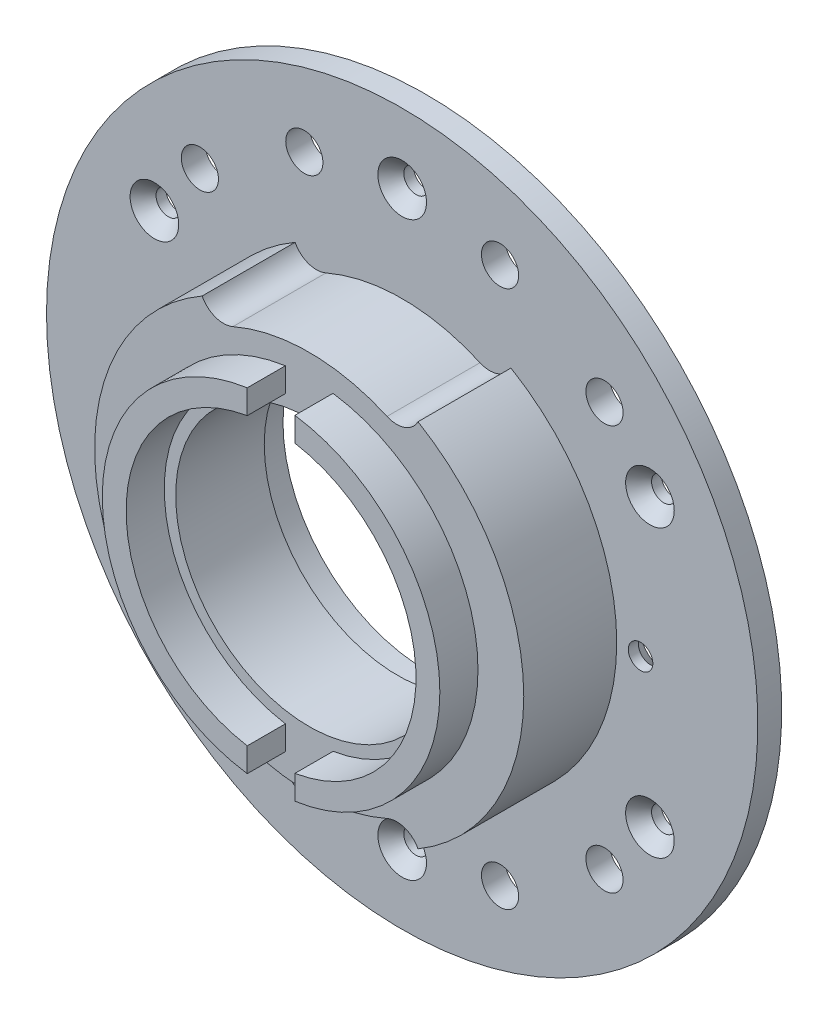
from build123d import *

# Parameters (mm, degrees)
SKETCH1_R               = 28.575
BOSS_EXTRUDE1_DEPTH     = 4.7625
SKETCH2_R               = 17.78
CUT_EXTRUDE1_DEPTH      = 5.7625
SKETCH9_R               = 28.575
SKETCH9_R_2             = 17.78
BOSS_EXTRUDE4_DEPTH     = 7.62
SKETCH4_R               = 22.479
SKETCH4_R_2             = 19.304
BOSS_EXTRUDE2_DEPTH     = 5.08
SKETCH5_W               = 6.35
SKETCH5_H               = 50.8
CUT_EXTRUDE3_DEPTH      = 5.08
CUT_EXTRUDE4_DEPTH      = 13.3825
SKETCH10_R              = 19.05
CUT_EXTRUDE5_DEPTH      = 0.59182
SKETCH11_R              = 47.371
SKETCH11_R_2            = 19.05
BOSS_EXTRUDE5_DEPTH     = 3.175
CIRPATTERN1_COUNT       = 6
SKETCH19_R              = 2.4765
CUT_EXTRUDE7_DEPTH      = 21.6375
CIRPATTERN2_COUNT       = 2
CIRPATTERN2_ANGLE       = 25
MIRROR3_COPY_1_SKETCH_R = 2.4765
MIRROR3_COPY_1_DEPTH    = 21.6375
MIRROR4_COPY_1_SKETCH_R = 2.4765
MIRROR4_COPY_1_DEPTH    = 21.6375
MIRROR4_COPY_2_SKETCH_R = 2.4765
MIRROR4_COPY_2_DEPTH    = 21.6375
MIRROR4_COPY_3_SKETCH_R = 2.4765
MIRROR4_COPY_3_DEPTH    = 21.6375


with BuildPart() as part:
    # Sketch1 → Boss-Extrude1 (new body)
    with BuildSketch(Plane.XY):
        Circle(SKETCH1_R)
    extrude(amount=BOSS_EXTRUDE1_DEPTH)

    # Sketch2 → Cut-Extrude1 (cut, through all)
    with BuildSketch(Plane.XY.offset(4.7625)):
        Circle(SKETCH2_R)
    extrude(amount=-CUT_EXTRUDE1_DEPTH, mode=Mode.SUBTRACT)

    # Sketch9 → Boss-Extrude4 (add)
    with BuildSketch(Plane(origin=(0, 0, 0), x_dir=(-1, 0, 0), z_dir=(0, 0, -1))):
        Circle(SKETCH9_R)
        Circle(SKETCH9_R_2, mode=Mode.SUBTRACT)
    extrude(amount=BOSS_EXTRUDE4_DEPTH)

    # Sketch4 → Boss-Extrude2 (add)
    with BuildSketch(Plane.XY.offset(4.7625)):
        Circle(SKETCH4_R)
        Circle(SKETCH4_R_2, mode=Mode.SUBTRACT)
    extrude(amount=BOSS_EXTRUDE2_DEPTH)

    # Sketch5 → Cut-Extrude3 (cut)
    with BuildSketch(Plane.XY.offset(9.8425)):
        Rectangle(SKETCH5_W, SKETCH5_H)
    extrude(amount=-CUT_EXTRUDE3_DEPTH, mode=Mode.SUBTRACT)

    # Sketch7 → Cut-Extrude4 (cut, through all)
    with BuildSketch(Plane.XY.offset(4.7625)):
        with BuildLine():
            ThreePointArc((12.960022594, 28.984484028), (0.147829333, 31.749655848), (-12.689557657, 29.103910845))
            ThreePointArc((-12.689557657, 29.103910845), (-14.330992976, 24.924563995), (-10.151646126, 23.283128676))
            ThreePointArc((-10.151646126, 23.283128676), (0.118263466, 25.399724679), (10.368018075, 23.187587222))
            ThreePointArc((10.368018075, 23.187587222), (14.562468737, 24.790033366), (12.960022594, 28.984484028))
        make_face()
    cut_extrude4 = extrude(amount=-CUT_EXTRUDE4_DEPTH, mode=Mode.SUBTRACT)

    # Mirror1: Cut-Extrude4 across plane
    add(cut_extrude4.mirror(Plane.ZX), mode=Mode.SUBTRACT)

    # Sketch10 → Cut-Extrude5 (cut)
    with BuildSketch(Plane(origin=(0, 0, -7.62), x_dir=(-1, 0, 0), z_dir=(0, 0, -1))):
        Circle(SKETCH10_R)
    extrude(amount=-CUT_EXTRUDE5_DEPTH, mode=Mode.SUBTRACT)

    # Sketch11 → Boss-Extrude5 (add)
    with BuildSketch(Plane(origin=(0, 0, -7.62), x_dir=(-1, 0, 0), z_dir=(0, 0, -1))):
        Circle(SKETCH11_R)
        Circle(SKETCH11_R_2, mode=Mode.SUBTRACT)
    extrude(amount=BOSS_EXTRUDE5_DEPTH)

    # Sketch12 → CSK for #4 Flat Head Socket Cap Screw1 (revolve, cut)
    with BuildSketch(Plane(origin=(-31.75, 0, -10.795), x_dir=(0, 1, 0), z_dir=(1, 0, 0))):
        Polygon((0, 0), (0, 6.060574487), (1.63195, 5.08), (1.63195, 1.848124365), (3.2385, 0), align=None)
    csk_for_4_flat_head_socket_cap_screw1 = revolve(axis=Axis((-31.75, 0, -17.145), (0, 0, 1)), mode=Mode.SUBTRACT)

    # Mirror2: CSK for #4 Flat Head Socket Cap Screw1 across plane
    add(csk_for_4_flat_head_socket_cap_screw1.mirror(Plane(origin=(0, 0, 0), x_dir=(0, 0, 1), z_dir=(1, 0, 0))), mode=Mode.SUBTRACT)

    # Sketch16 → CSK for #4 Flat Head Socket Cap Screw3 (revolve, cut)
    with BuildSketch(Plane(origin=(0, 38.1, -7.62), x_dir=(0, -1, 0), z_dir=(1, 0, 0))):
        Polygon((0, 0), (0, 4.155574487), (1.63195, 3.175), (1.63195, 1.848124365), (3.2385, 0), align=None)
    csk_for_4_flat_head_socket_cap_screw3 = revolve(axis=Axis((0, 38.1, -1.27), (0, 0, -1)), mode=Mode.SUBTRACT)

    # CirPattern1: CSK for #4 Flat Head Socket Cap Screw3 ×6 about axis
    cirpattern1_axis = Axis((0, 0, 0), (0, 0, 1))
    for i in range(1, CIRPATTERN1_COUNT):
        add(csk_for_4_flat_head_socket_cap_screw3.rotate(cirpattern1_axis, i * 360 / CIRPATTERN1_COUNT), mode=Mode.SUBTRACT)

    # Sketch19 → Cut-Extrude7 (cut, through all)
    with BuildSketch(Plane(origin=(0, 0, -10.795), x_dir=(-1, 0, 0), z_dir=(0, 0, -1))):
        with Locations((13.030967461, 35.802288852)):
            Circle(SKETCH19_R)
    cut_extrude7 = extrude(amount=-CUT_EXTRUDE7_DEPTH, mode=Mode.SUBTRACT)

    # CirPattern2: Cut-Extrude7 ×2 about axis
    cirpattern2_axis = Axis((0, 0, -10.795), (0, 0, 1))
    for i in range(1, CIRPATTERN2_COUNT):
        add(cut_extrude7.rotate(cirpattern2_axis, i * CIRPATTERN2_ANGLE / (CIRPATTERN2_COUNT - 1)), mode=Mode.SUBTRACT)

    # Mirror3: Cut-Extrude7 across plane
    add(cut_extrude7.mirror(Plane(origin=(0, 0, 0), x_dir=(0, 0, 1), z_dir=(1, 0, 0))), mode=Mode.SUBTRACT)

    # Mirror3 copy 1 sketch → Mirror3 copy 1 (cut, through all)
    with BuildSketch(Plane(origin=(0, 0, -10.795), x_dir=(0.906307787, -0.422618262, 0), z_dir=(0, 0, -1))):
        with Locations((13.030967461, -35.802288852)):
            Circle(MIRROR3_COPY_1_SKETCH_R)
    extrude(amount=-MIRROR3_COPY_1_DEPTH, mode=Mode.SUBTRACT)

    # Mirror4: Cut-Extrude7 across plane
    add(cut_extrude7.mirror(Plane.ZX), mode=Mode.SUBTRACT)

    # Mirror4 copy 1 sketch → Mirror4 copy 1 (cut, through all)
    with BuildSketch(Plane(origin=(0, 0, -10.795), x_dir=(1, 0, 0), z_dir=(0, 0, -1))):
        with Locations((13.030967461, 35.802288852)):
            Circle(MIRROR4_COPY_1_SKETCH_R)
    extrude(amount=-MIRROR4_COPY_1_DEPTH, mode=Mode.SUBTRACT)

    # Mirror4 copy 2 sketch → Mirror4 copy 2 (cut, through all)
    with BuildSketch(Plane(origin=(0, 0, -10.795), x_dir=(0.906307787, 0.422618262, 0), z_dir=(0, 0, -1))):
        with Locations((13.030967461, 35.802288852)):
            Circle(MIRROR4_COPY_2_SKETCH_R)
    extrude(amount=-MIRROR4_COPY_2_DEPTH, mode=Mode.SUBTRACT)

    # Mirror4 copy 3 sketch → Mirror4 copy 3 (cut, through all)
    with BuildSketch(Plane(origin=(0, 0, -10.795), x_dir=(-0.906307787, 0.422618262, 0), z_dir=(0, 0, -1))):
        with Locations((13.030967461, -35.802288852)):
            Circle(MIRROR4_COPY_3_SKETCH_R)
    extrude(amount=-MIRROR4_COPY_3_DEPTH, mode=Mode.SUBTRACT)


solid = part.part
